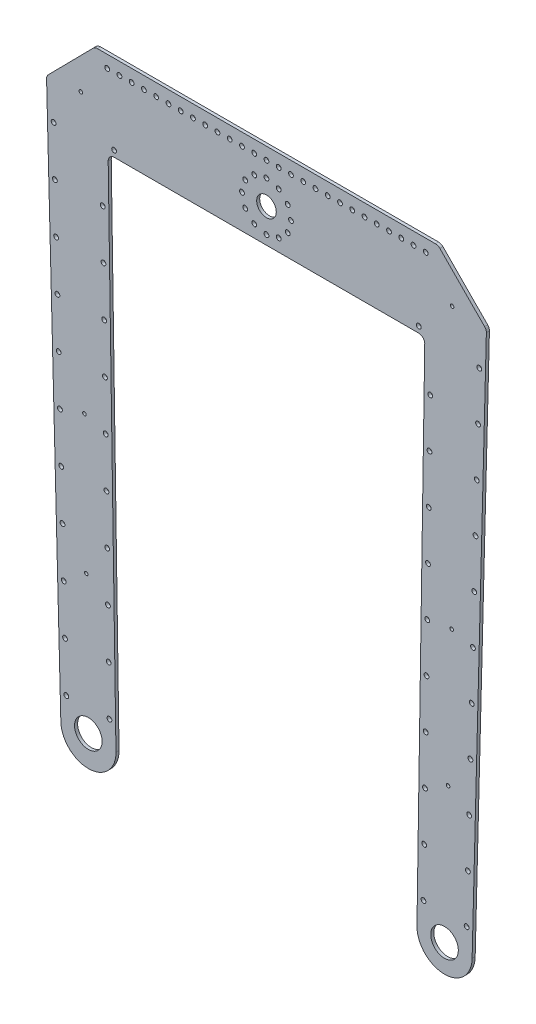
from build123d import *

# Parameters (mm, degrees)
SKETCH1_R           = 14.2875
SKETCH1_R_2         = 2.4892
SKETCH1_R_3         = 1.8288
SKETCH1_R_4         = 10.16
BOSS_EXTRUDE1_DEPTH = 3.175
FILLET1_R           = 6.35


with BuildPart() as part:
    # Sketch1 → Boss-Extrude1 (new body)
    with BuildSketch(Plane.XY):
        with BuildLine():
            Line((431.8, 25.4), (76.2, 25.4))
            Line((76.2, 25.4), (26.059319149, -25.4))
            Line((26.059319149, -25.4), (40.894, -596.9))
            ThreePointArc((40.894, -596.9), (69.687933371, -625.474161286), (98.040645192, -596.462146109))
            Line((98.040645192, -596.462146109), (89.873122894, -63.5))
            Line((89.873122894, -63.5), (418.126877106, -63.5))
            Line((418.126877106, -63.5), (409.959354808, -596.462146109))
            ThreePointArc((409.959354808, -596.462146109), (438.312066629, -625.474161286), (467.106, -596.9))
            Line((467.106, -596.9), (481.940680851, -25.4))
            Line((481.940680851, -25.4), (431.8, 25.4))
        make_face()
        with Locations((69.402383578, -593.962825081)):
            Circle(SKETCH1_R, mode=Mode.SUBTRACT)
        with Locations((46.582379595, -571.328944019)):
            Circle(SKETCH1_R_2, mode=Mode.SUBTRACT)
        with Locations((91.28656025, -570.142707564)):
            Circle(SKETCH1_R_2, mode=Mode.SUBTRACT)
        with Locations((45.264185314, -520.546049618)):
            Circle(SKETCH1_R_2, mode=Mode.SUBTRACT)
        with Locations((43.945991034, -469.763155216)):
            Circle(SKETCH1_R_2, mode=Mode.SUBTRACT)
        with Locations((90.508153333, -519.348671668)):
            Circle(SKETCH1_R_2, mode=Mode.SUBTRACT)
        with Locations((89.729746417, -468.554635771)):
            Circle(SKETCH1_R_2, mode=Mode.SUBTRACT)
        with Locations((67.240460084, -451.479225721)):
            Circle(SKETCH1_R_3, mode=Mode.SUBTRACT)
        with Locations((42.627796754, -418.980260814)):
            Circle(SKETCH1_R_2, mode=Mode.SUBTRACT)
        with Locations((88.9513395, -417.760599874)):
            Circle(SKETCH1_R_2, mode=Mode.SUBTRACT)
        with Locations((41.309602474, -368.197366412)):
            Circle(SKETCH1_R_2, mode=Mode.SUBTRACT)
        with Locations((39.991408193, -317.41447201)):
            Circle(SKETCH1_R_2, mode=Mode.SUBTRACT)
        with Locations((65.373280571, -308.991459085)):
            Circle(SKETCH1_R_3, mode=Mode.SUBTRACT)
        with Locations((88.172932583, -366.966563978)):
            Circle(SKETCH1_R_2, mode=Mode.SUBTRACT)
        with Locations((87.394525667, -316.172528081)):
            Circle(SKETCH1_R_2, mode=Mode.SUBTRACT)
        with Locations((416.71343975, -570.142707564)):
            Circle(SKETCH1_R_2, mode=Mode.SUBTRACT)
        with Locations((438.531, -596.9)):
            Circle(SKETCH1_R, mode=Mode.SUBTRACT)
        with Locations((461.417620405, -571.328944019)):
            Circle(SKETCH1_R_2, mode=Mode.SUBTRACT)
        with Locations((417.491846667, -519.348671668)):
            Circle(SKETCH1_R_2, mode=Mode.SUBTRACT)
        with Locations((418.270253583, -468.554635771)):
            Circle(SKETCH1_R_2, mode=Mode.SUBTRACT)
        with Locations((462.735814686, -520.546049618)):
            Circle(SKETCH1_R_2, mode=Mode.SUBTRACT)
        with Locations((464.054008966, -469.763155216)):
            Circle(SKETCH1_R_2, mode=Mode.SUBTRACT)
        with Locations((419.0486605, -417.760599874)):
            Circle(SKETCH1_R_2, mode=Mode.SUBTRACT)
        with Locations((442.219071981, -454.447733872)):
            Circle(SKETCH1_R_3, mode=Mode.SUBTRACT)
        with Locations((465.372203246, -418.980260814)):
            Circle(SKETCH1_R_2, mode=Mode.SUBTRACT)
        with Locations((419.827067417, -366.966563978)):
            Circle(SKETCH1_R_2, mode=Mode.SUBTRACT)
        with Locations((420.605474333, -316.172528081)):
            Circle(SKETCH1_R_2, mode=Mode.SUBTRACT)
        with Locations((466.690397526, -368.197366412)):
            Circle(SKETCH1_R_2, mode=Mode.SUBTRACT)
        with Locations((445.916762629, -311.995717095)):
            Circle(SKETCH1_R_3, mode=Mode.SUBTRACT)
        with Locations((468.008591807, -317.41447201)):
            Circle(SKETCH1_R_2, mode=Mode.SUBTRACT)
        with Locations((38.673213913, -266.631577608)):
            Circle(SKETCH1_R_2, mode=Mode.SUBTRACT)
        with Locations((86.61611875, -265.378492184)):
            Circle(SKETCH1_R_2, mode=Mode.SUBTRACT)
        with Locations((37.355019633, -215.848683206)):
            Circle(SKETCH1_R_2, mode=Mode.SUBTRACT)
        with Locations((36.036825353, -165.065788804)):
            Circle(SKETCH1_R_2, mode=Mode.SUBTRACT)
        with Locations((85.837711834, -214.584456288)):
            Circle(SKETCH1_R_2, mode=Mode.SUBTRACT)
        with Locations((85.059304917, -163.790420391)):
            Circle(SKETCH1_R_2, mode=Mode.SUBTRACT)
        with Locations((34.718631073, -114.282894402)):
            Circle(SKETCH1_R_2, mode=Mode.SUBTRACT)
        with Locations((33.400436792, -63.5)):
            Circle(SKETCH1_R_2, mode=Mode.SUBTRACT)
        with Locations((84.280898001, -112.996384494)):
            Circle(SKETCH1_R_2, mode=Mode.SUBTRACT)
        with Locations((61.612453458, -21.996099229)):
            Circle(SKETCH1_R_3, mode=Mode.SUBTRACT)
        with Locations((88.9, 12.7)):
            Circle(SKETCH1_R_2, mode=Mode.SUBTRACT)
        with Locations((101.6, 12.7)):
            Circle(SKETCH1_R_2, mode=Mode.SUBTRACT)
        with Locations((114.3, 12.7)):
            Circle(SKETCH1_R_2, mode=Mode.SUBTRACT)
        with Locations((127, 12.7)):
            Circle(SKETCH1_R_2, mode=Mode.SUBTRACT)
        with Locations((139.7, 12.7)):
            Circle(SKETCH1_R_2, mode=Mode.SUBTRACT)
        with Locations((152.4, 12.7)):
            Circle(SKETCH1_R_2, mode=Mode.SUBTRACT)
        with Locations((165.1, 12.7)):
            Circle(SKETCH1_R_2, mode=Mode.SUBTRACT)
        with Locations((177.8, 12.7)):
            Circle(SKETCH1_R_2, mode=Mode.SUBTRACT)
        with Locations((190.5, 12.7)):
            Circle(SKETCH1_R_2, mode=Mode.SUBTRACT)
        with Locations((203.2, 12.7)):
            Circle(SKETCH1_R_2, mode=Mode.SUBTRACT)
        with Locations((215.9, 12.7)):
            Circle(SKETCH1_R_2, mode=Mode.SUBTRACT)
        with Locations((228.6, 12.7)):
            Circle(SKETCH1_R_2, mode=Mode.SUBTRACT)
        with Locations((241.3, 12.7)):
            Circle(SKETCH1_R_2, mode=Mode.SUBTRACT)
        with Locations((421.38388125, -265.378492184)):
            Circle(SKETCH1_R_2, mode=Mode.SUBTRACT)
        with Locations((469.326786087, -266.631577608)):
            Circle(SKETCH1_R_2, mode=Mode.SUBTRACT)
        with Locations((422.162288166, -214.584456288)):
            Circle(SKETCH1_R_2, mode=Mode.SUBTRACT)
        with Locations((422.940695083, -163.790420391)):
            Circle(SKETCH1_R_2, mode=Mode.SUBTRACT)
        with Locations((470.644980367, -215.848683206)):
            Circle(SKETCH1_R_2, mode=Mode.SUBTRACT)
        with Locations((471.963174647, -165.065788804)):
            Circle(SKETCH1_R_2, mode=Mode.SUBTRACT)
        with Locations((254, 12.7)):
            Circle(SKETCH1_R_2, mode=Mode.SUBTRACT)
        with Locations((266.7, 12.7)):
            Circle(SKETCH1_R_2, mode=Mode.SUBTRACT)
        with Locations((279.4, 12.7)):
            Circle(SKETCH1_R_2, mode=Mode.SUBTRACT)
        with Locations((292.1, 12.7)):
            Circle(SKETCH1_R_2, mode=Mode.SUBTRACT)
        with Locations((304.8, 12.7)):
            Circle(SKETCH1_R_2, mode=Mode.SUBTRACT)
        with Locations((317.5, 12.7)):
            Circle(SKETCH1_R_2, mode=Mode.SUBTRACT)
        with Locations((330.2, 12.7)):
            Circle(SKETCH1_R_2, mode=Mode.SUBTRACT)
        with Locations((342.9, 12.7)):
            Circle(SKETCH1_R_2, mode=Mode.SUBTRACT)
        with Locations((355.6, 12.7)):
            Circle(SKETCH1_R_2, mode=Mode.SUBTRACT)
        with Locations((423.719101999, -112.996384494)):
            Circle(SKETCH1_R_2, mode=Mode.SUBTRACT)
        with Locations((473.281368927, -114.282894402)):
            Circle(SKETCH1_R_2, mode=Mode.SUBTRACT)
        with Locations((474.599563208, -63.5)):
            Circle(SKETCH1_R_2, mode=Mode.SUBTRACT)
        with Locations((368.3, 12.7)):
            Circle(SKETCH1_R_2, mode=Mode.SUBTRACT)
        with Locations((381, 12.7)):
            Circle(SKETCH1_R_2, mode=Mode.SUBTRACT)
        with Locations((393.7, 12.7)):
            Circle(SKETCH1_R_2, mode=Mode.SUBTRACT)
        with Locations((406.4, 12.7)):
            Circle(SKETCH1_R_2, mode=Mode.SUBTRACT)
        with Locations((419.1, 12.7)):
            Circle(SKETCH1_R_2, mode=Mode.SUBTRACT)
        with Locations((446.387546542, -21.996099229)):
            Circle(SKETCH1_R_3, mode=Mode.SUBTRACT)
        with Locations((266.7, -6.577954744)):
            Circle(SKETCH1_R_2, mode=Mode.SUBTRACT)
        with Locations((254, -3.175)):
            Circle(SKETCH1_R_2, mode=Mode.SUBTRACT)
        with Locations((411.873443795, -57.15)):
            Circle(SKETCH1_R_2, mode=Mode.SUBTRACT)
        with Locations((96.126556205, -57.15)):
            Circle(SKETCH1_R_2, mode=Mode.SUBTRACT)
        with Locations((232.002954744, -41.275)):
            Circle(SKETCH1_R_2, mode=Mode.SUBTRACT)
        with Locations((241.3, -50.572045256)):
            Circle(SKETCH1_R_2, mode=Mode.SUBTRACT)
        with Locations((228.6, -28.575)):
            Circle(SKETCH1_R_2, mode=Mode.SUBTRACT)
        with Locations((232.002954744, -15.875)):
            Circle(SKETCH1_R_2, mode=Mode.SUBTRACT)
        with Locations((241.3, -6.577954744)):
            Circle(SKETCH1_R_2, mode=Mode.SUBTRACT)
        with Locations((254, -53.975)):
            Circle(SKETCH1_R_2, mode=Mode.SUBTRACT)
        with Locations((266.7, -50.572045256)):
            Circle(SKETCH1_R_2, mode=Mode.SUBTRACT)
        with Locations((275.997045256, -41.275)):
            Circle(SKETCH1_R_2, mode=Mode.SUBTRACT)
        with Locations((254, -28.575)):
            Circle(SKETCH1_R_4, mode=Mode.SUBTRACT)
        with Locations((279.4, -28.575)):
            Circle(SKETCH1_R_2, mode=Mode.SUBTRACT)
        with Locations((275.997045256, -15.875)):
            Circle(SKETCH1_R_2, mode=Mode.SUBTRACT)
    extrude(amount=BOSS_EXTRUDE1_DEPTH)

    # Fillet1
    fillet1_edges = [part.edges().sort_by_distance(p)[0] for p in [
        (26.059319149, -25.4, 1.5875),
        (76.2, 25.4, 1.5875),
        (431.8, 25.4, 1.5875),
        (481.940680851, -25.4, 1.5875),
        (418.126877106, -63.5, 1.5875),
        (89.873122894, -63.5, 1.5875),
    ]]
    fillet(fillet1_edges, radius=FILLET1_R)


solid = part.part
